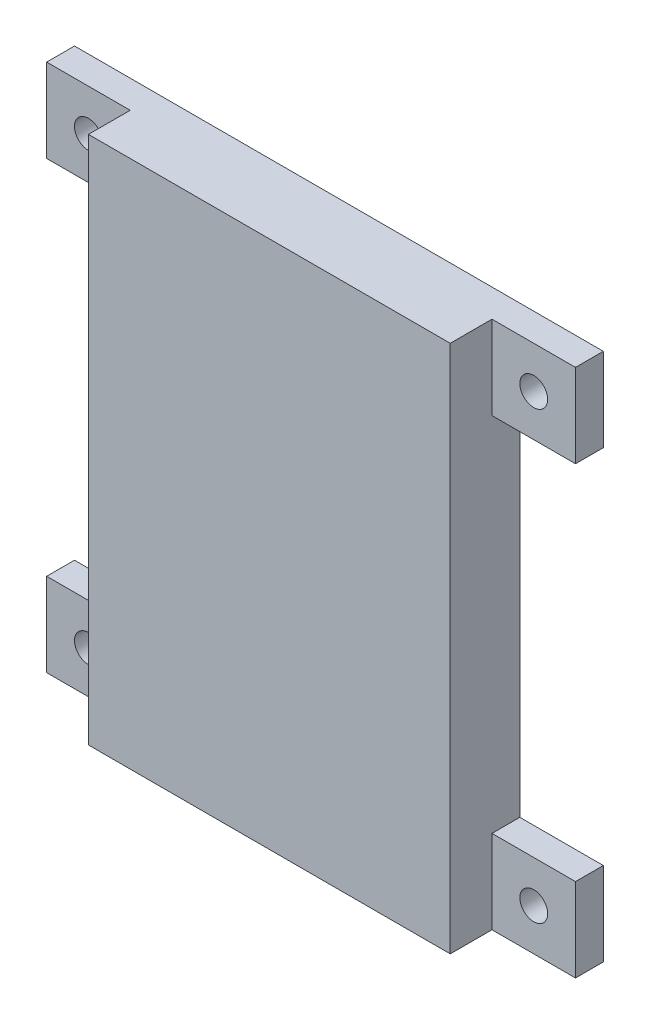
from build123d import *

# Parameters (mm, degrees)
SKETCH_1_W          = 26
SKETCH_1_H          = 38
EXTRUDE_1_DEPTH     = 5
SKETCH_2_W          = 22
SKETCH_2_H          = 34
CUT_EXTRUDE_1_DEPTH = 3
SKETCH_4_W          = 6
SKETCH_4_H          = 6
EXTRUDE_2_DEPTH     = 2
SKETCH_5_R          = 1
CUT_EXTRUDE_4_DEPTH = 2


with BuildPart() as part:
    # ｽｹｯﾁ1 → ﾎﾞｽ - 押し出し1 (new body)
    with BuildSketch(Plane.XY):
        Rectangle(SKETCH_1_W, SKETCH_1_H)
    extrude(amount=EXTRUDE_1_DEPTH)

    # ｽｹｯﾁ2 → ｶｯﾄ - 押し出し1 (cut)
    with BuildSketch(Plane.XY):
        Rectangle(SKETCH_2_W, SKETCH_2_H)
    extrude(amount=CUT_EXTRUDE_1_DEPTH, mode=Mode.SUBTRACT)

    # ｽｹｯﾁ4 → ﾎﾞｽ - 押し出し2 (add)
    with BuildSketch(Plane.XY):
        with Locations((16, 16)):
            Rectangle(SKETCH_4_W, SKETCH_4_H)
        with Locations((16, -16)):
            Rectangle(SKETCH_4_W, SKETCH_4_H)
        with Locations((-16, -16)):
            Rectangle(SKETCH_4_W, SKETCH_4_H)
        with Locations((-16, 16)):
            Rectangle(SKETCH_4_W, SKETCH_4_H)
    extrude(amount=EXTRUDE_2_DEPTH)

    # ｽｹｯﾁ5 → ｶｯﾄ - 押し出し4 (cut)
    with BuildSketch(Plane.XY):
        with Locations((-16, 16)):
            Circle(SKETCH_5_R)
        with Locations((-16, -16)):
            Circle(SKETCH_5_R)
        with Locations((16, -16)):
            Circle(SKETCH_5_R)
        with Locations((16, 16)):
            Circle(SKETCH_5_R)
    extrude(amount=CUT_EXTRUDE_4_DEPTH, mode=Mode.SUBTRACT)


solid = part.part
